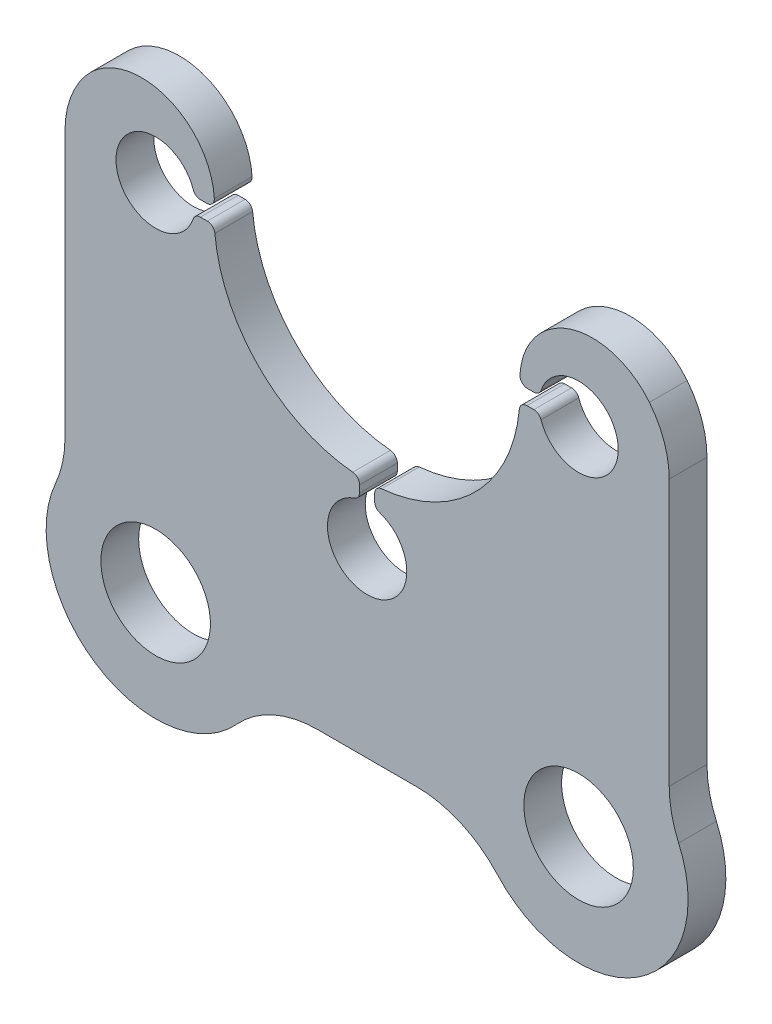
from build123d import *

# Parameters (mm, degrees)
SKETCH1_R      = 7.25
EXTRUDE1_DEPTH = 5


with BuildPart() as part:
    # Sketch1 → Extrude1 (new body)
    with BuildSketch(Plane.XY):
        with BuildLine():
            Line((21.155672998, -1), (22.078640359, -1))
            ThreePointArc((22.078640359, -1), (22.661735548, -1.18759616), (23.026057901, -1.68))
            ThreePointArc((23.026057901, -1.68), (33.25, 0), (23.026057901, 1.68))
            ThreePointArc((23.026057901, 1.68), (22.661735548, 1.18759616), (22.078640359, 1))
            Line((22.078640359, 1), (21.2294652, 1))
            ThreePointArc((21.2294652, 1), (20.50121081, 1.314693102), (20.231309687, 2.060708911))
            ThreePointArc((20.231309687, 2.060708911), (26.941055993, 10.661478857), (37.377512662, 7.48747329))
            ThreePointArc((37.377512662, 7.48747329), (39.325417254, 3.966727118), (40, 0))
            Line((40, 0), (40, -35.220781011))
            ThreePointArc((40, -35.220781011), (40.315942047, -38.231179655), (41.25, -41.110390505))
            ThreePointArc((41.25, -41.110390505), (35.920463529, -59.145627093), (17.267456033, -56.75))
            ThreePointArc((17.267456033, -56.75), (12.403259363, -53.240569394), (6.534912066, -52))
            Line((6.534912066, -52), (-6.534912066, -52))
            ThreePointArc((-6.534912066, -52), (-12.403259363, -53.240569394), (-17.267456033, -56.75))
            ThreePointArc((-17.267456033, -56.75), (-35.920463529, -59.145627093), (-41.25, -41.110390505))
            ThreePointArc((-41.25, -41.110390505), (-40.315942047, -38.231179655), (-40, -35.220781011))
            Line((-40, -35.220781011), (-40, 0))
            ThreePointArc((-40, 0), (-39.325417254, 3.966727118), (-37.377512662, 7.48747329))
            ThreePointArc((-37.377512662, 7.48747329), (-26.941055993, 10.661478857), (-20.231309687, 2.060708911))
            ThreePointArc((-20.231309687, 2.060708911), (-20.50121081, 1.314693102), (-21.2294652, 1))
            Line((-21.2294652, 1), (-22.078640359, 1))
            ThreePointArc((-22.078640359, 1), (-22.661735548, 1.18759616), (-23.026057901, 1.68))
            ThreePointArc((-23.026057901, 1.68), (-33.25, 0), (-23.026057901, -1.68))
            ThreePointArc((-23.026057901, -1.68), (-22.661735548, -1.18759616), (-22.078640359, -1))
            Line((-22.078640359, -1), (-21.155672998, -1))
            ThreePointArc((-21.155672998, -1), (-20.482663952, -1.26036575), (-20.160111916, -1.905882353))
            ThreePointArc((-20.160111916, -1.905882353), (-14.318912319, -14.318912319), (-1.905882353, -20.160111916))
            ThreePointArc((-1.905882353, -20.160111916), (-1.26036575, -20.482663952), (-1, -21.155672998))
            Line((-1, -21.155672998), (-1, -22.078640359))
            ThreePointArc((-1, -22.078640359), (-1.18759616, -22.661735548), (-1.68, -23.026057901))
            ThreePointArc((-1.68, -23.026057901), (0, -33.25), (1.68, -23.026057901))
            ThreePointArc((1.68, -23.026057901), (1.18759616, -22.661735548), (1, -22.078640359))
            Line((1, -22.078640359), (1, -21.155672998))
            ThreePointArc((1, -21.155672998), (1.26036575, -20.482663952), (1.905882353, -20.160111916))
            ThreePointArc((1.905882353, -20.160111916), (14.318912319, -14.318912319), (20.160111916, -1.905882353))
            ThreePointArc((20.160111916, -1.905882353), (20.482663952, -1.26036575), (21.155672998, -1))
        make_face()
        with Locations((28, -47)):
            Circle(SKETCH1_R, mode=Mode.SUBTRACT)
        with Locations((-28, -47)):
            Circle(SKETCH1_R, mode=Mode.SUBTRACT)
    extrude(amount=EXTRUDE1_DEPTH)


solid = part.part
